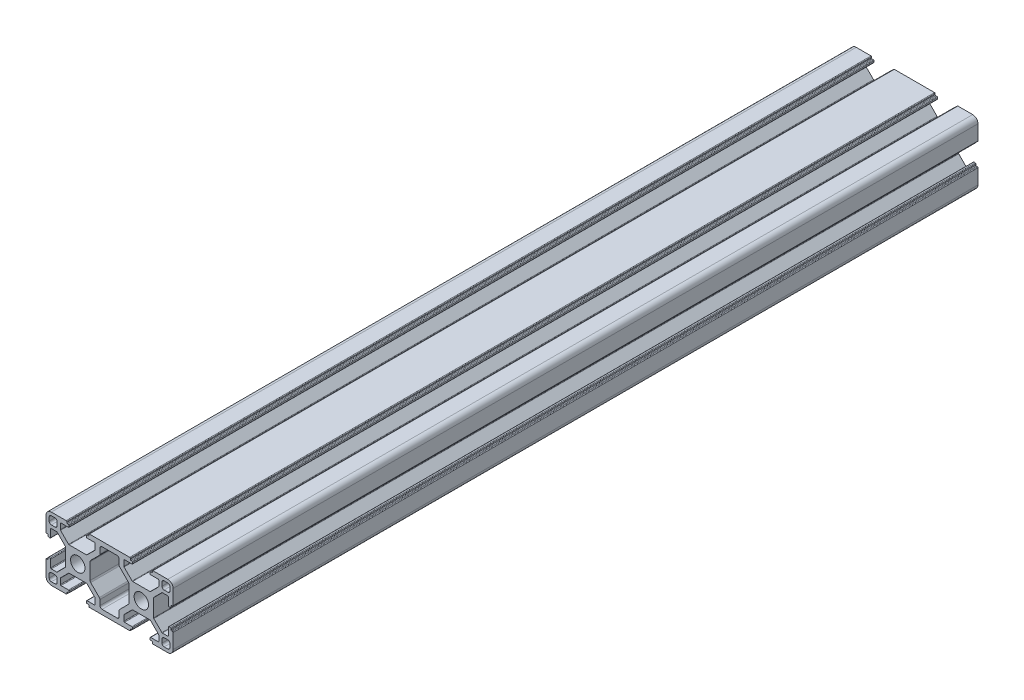
from build123d import *

# Parameters (mm, degrees)
MODEL_R         = 3.4
EXTRUDE_1_DEPTH = 380


with BuildPart() as part:
    # Model → 凸台-拉伸1 (new body)
    with BuildSketch(Plane.XY):
        with BuildLine():
            Line((147.993901934, 59.249179347), (148.493901934, 59.249179347))
            ThreePointArc((148.493901934, 59.249179347), (148.706033968, 59.337047312), (148.793901934, 59.549179347))
            Line((148.793901934, 59.549179347), (148.793901934, 59.949179347))
            ThreePointArc((148.793901934, 59.949179347), (148.881769899, 60.161311381), (149.093901934, 60.249179347))
            Line((149.093901934, 60.249179347), (156.093901934, 60.249179347))
            ThreePointArc((156.093901934, 60.249179347), (157.861668887, 59.5169463), (158.593901934, 57.749179346))
            Line((158.593901934, 57.749179346), (158.593901934, 50.749179347))
            ThreePointArc((158.593901934, 50.749179347), (158.506033968, 50.537047312), (158.293901934, 50.449179347))
            Line((158.293901934, 50.449179347), (157.893901934, 50.449179347))
            ThreePointArc((157.893901934, 50.449179347), (157.6817699, 50.361311381), (157.593901934, 50.149179347))
            Line((157.593901934, 50.149179347), (157.593901934, 49.649179347))
            ThreePointArc((157.593901934, 49.649179347), (157.506033968, 49.437047312), (157.293901934, 49.349179347))
            Line((157.293901934, 49.349179347), (156.693901934, 49.349179347))
            ThreePointArc((156.693901934, 49.349179347), (156.4817699, 49.437047312), (156.393901934, 49.649179347))
            Line((156.393901934, 49.649179347), (156.393901934, 53.199179347))
            ThreePointArc((156.393901934, 53.199179347), (156.306033968, 53.411311381), (156.093901934, 53.499179347))
            Line((156.093901934, 53.499179347), (153.523800921, 53.499179347))
            ThreePointArc((153.523800921, 53.499179347), (153.408995891, 53.476343206), (153.311668887, 53.411311381))
            Line((153.311668887, 53.411311381), (149.4817699, 49.581412394))
            ThreePointArc((149.4817699, 49.581412394), (149.416738074, 49.484085389), (149.393901934, 49.369280359))
            Line((149.393901934, 49.369280359), (149.393901934, 45.249179347))
            Line((149.393901934, 45.249179347), (149.393901934, 41.129078334))
            ThreePointArc((149.393901934, 41.129078334), (149.416738074, 41.014273304), (149.4817699, 40.9169463))
            Line((149.4817699, 40.9169463), (153.311668887, 37.087047312))
            ThreePointArc((153.311668887, 37.087047312), (153.408995891, 37.022015487), (153.523800921, 36.999179347))
            Line((153.523800921, 36.999179347), (156.093901934, 36.999179347))
            ThreePointArc((156.093901934, 36.999179347), (156.306033968, 37.087047312), (156.393901934, 37.299179347))
            Line((156.393901934, 37.299179347), (156.393901934, 40.849179347))
            ThreePointArc((156.393901934, 40.849179347), (156.4817699, 41.061311381), (156.693901934, 41.149179347))
            Line((156.693901934, 41.149179347), (157.293901934, 41.149179347))
            ThreePointArc((157.293901934, 41.149179347), (157.506033968, 41.061311381), (157.593901934, 40.849179347))
            Line((157.593901934, 40.849179347), (157.593901934, 40.349179347))
            ThreePointArc((157.593901934, 40.349179347), (157.6817699, 40.137047312), (157.893901934, 40.049179347))
            Line((157.893901934, 40.049179347), (158.293901934, 40.049179347))
            ThreePointArc((158.293901934, 40.049179347), (158.506033968, 39.961311381), (158.593901934, 39.749179347))
            Line((158.593901934, 39.749179347), (158.593901934, 32.749179347))
            ThreePointArc((158.593901934, 32.749179347), (157.861668887, 30.981412394), (156.093901934, 30.249179347))
            Line((156.093901934, 30.249179347), (149.093901934, 30.249179347))
            ThreePointArc((149.093901934, 30.249179347), (148.881769899, 30.337047312), (148.793901934, 30.549179346))
            Line((148.793901934, 30.549179346), (148.793901934, 30.949179346))
            ThreePointArc((148.793901934, 30.949179346), (148.706033968, 31.161311381), (148.493901934, 31.249179347))
            Line((148.493901934, 31.249179347), (147.993901934, 31.249179347))
            ThreePointArc((147.993901934, 31.249179347), (147.7817699, 31.337047312), (147.693901934, 31.549179347))
            Line((147.693901934, 31.549179347), (147.693901934, 32.149179347))
            ThreePointArc((147.693901934, 32.149179347), (147.7817699, 32.361311381), (147.993901934, 32.449179347))
            Line((147.993901934, 32.449179347), (151.543901934, 32.449179347))
            ThreePointArc((151.543901934, 32.449179347), (151.756033968, 32.537047312), (151.843901934, 32.749179347))
            Line((151.843901934, 32.749179347), (151.843901934, 35.319280359))
            ThreePointArc((151.843901934, 35.319280359), (151.821065794, 35.434085389), (151.756033968, 35.531412394))
            Line((151.756033968, 35.531412394), (147.926134981, 39.361311381))
            ThreePointArc((147.926134981, 39.361311381), (147.828807976, 39.426343206), (147.714002947, 39.449179347))
            Line((147.714002947, 39.449179347), (143.593901934, 39.449179347))
            Line((143.593901934, 39.449179347), (139.473800921, 39.449179347))
            ThreePointArc((139.473800921, 39.449179347), (139.358995892, 39.426343206), (139.261668887, 39.361311381))
            Line((139.261668887, 39.361311381), (135.4317699, 35.531412394))
            ThreePointArc((135.4317699, 35.531412394), (135.366738074, 35.434085389), (135.343901934, 35.319280359))
            Line((135.343901934, 35.319280359), (135.343901934, 32.749179347))
            ThreePointArc((135.343901934, 32.749179347), (135.4317699, 32.537047312), (135.643901934, 32.449179347))
            Line((135.643901934, 32.449179347), (139.193901934, 32.449179347))
            ThreePointArc((139.193901934, 32.449179347), (139.406033968, 32.361311381), (139.493901934, 32.149179347))
            Line((139.493901934, 32.149179347), (139.493901934, 31.549179347))
            ThreePointArc((139.493901934, 31.549179347), (139.406033968, 31.337047312), (139.193901934, 31.249179347))
            Line((139.193901934, 31.249179347), (138.693901934, 31.249179347))
            ThreePointArc((138.693901934, 31.249179347), (138.4817699, 31.161311381), (138.393901934, 30.949179346))
            Line((138.393901934, 30.949179346), (138.393901934, 30.549179347))
            ThreePointArc((138.393901934, 30.549179347), (138.306033968, 30.337047312), (138.093901934, 30.249179347))
            Line((138.093901934, 30.249179347), (119.093901934, 30.249179347))
            ThreePointArc((119.093901934, 30.249179347), (118.8817699, 30.337047312), (118.793901934, 30.549179347))
            Line((118.793901934, 30.549179347), (118.793901934, 30.949179346))
            ThreePointArc((118.793901934, 30.949179346), (118.706033968, 31.161311381), (118.493901934, 31.249179347))
            Line((118.493901934, 31.249179347), (117.993901934, 31.249179347))
            ThreePointArc((117.993901934, 31.249179347), (117.7817699, 31.337047312), (117.693901934, 31.549179347))
            Line((117.693901934, 31.549179347), (117.693901934, 32.149179347))
            ThreePointArc((117.693901934, 32.149179347), (117.7817699, 32.361311381), (117.993901934, 32.449179347))
            Line((117.993901934, 32.449179347), (121.543901934, 32.449179347))
            ThreePointArc((121.543901934, 32.449179347), (121.756033968, 32.537047312), (121.843901934, 32.749179347))
            Line((121.843901934, 32.749179347), (121.843901934, 35.319280359))
            ThreePointArc((121.843901934, 35.319280359), (121.821065794, 35.434085389), (121.756033968, 35.531412394))
            Line((121.756033968, 35.531412394), (117.926134981, 39.361311381))
            ThreePointArc((117.926134981, 39.361311381), (117.828807976, 39.426343206), (117.714002947, 39.449179347))
            Line((117.714002947, 39.449179347), (113.593901934, 39.449179347))
            Line((113.593901934, 39.449179347), (109.473800921, 39.449179347))
            ThreePointArc((109.473800921, 39.449179347), (109.358995892, 39.426343206), (109.261668887, 39.361311381))
            Line((109.261668887, 39.361311381), (105.4317699, 35.531412394))
            ThreePointArc((105.4317699, 35.531412394), (105.366738074, 35.434085389), (105.343901934, 35.319280359))
            Line((105.343901934, 35.319280359), (105.343901934, 32.749179347))
            ThreePointArc((105.343901934, 32.749179347), (105.4317699, 32.537047312), (105.643901934, 32.449179347))
            Line((105.643901934, 32.449179347), (109.193901934, 32.449179347))
            ThreePointArc((109.193901934, 32.449179347), (109.406033968, 32.361311381), (109.493901934, 32.149179347))
            Line((109.493901934, 32.149179347), (109.493901934, 31.549179347))
            ThreePointArc((109.493901934, 31.549179347), (109.406033968, 31.337047312), (109.193901934, 31.249179347))
            Line((109.193901934, 31.249179347), (108.693901934, 31.249179347))
            ThreePointArc((108.693901934, 31.249179347), (108.4817699, 31.161311381), (108.393901934, 30.949179346))
            Line((108.393901934, 30.949179346), (108.393901934, 30.549179346))
            ThreePointArc((108.393901934, 30.549179346), (108.306033968, 30.337047312), (108.093901934, 30.249179347))
            Line((108.093901934, 30.249179347), (101.093901934, 30.249179347))
            ThreePointArc((101.093901934, 30.249179347), (99.326134981, 30.981412394), (98.593901934, 32.749179347))
            Line((98.593901934, 32.749179347), (98.593901934, 39.749179347))
            ThreePointArc((98.593901934, 39.749179347), (98.6817699, 39.961311381), (98.893901934, 40.049179347))
            Line((98.893901934, 40.049179347), (99.293901934, 40.049179347))
            ThreePointArc((99.293901934, 40.049179347), (99.506033968, 40.137047312), (99.593901934, 40.349179347))
            Line((99.593901934, 40.349179347), (99.593901934, 40.849179347))
            ThreePointArc((99.593901934, 40.849179347), (99.6817699, 41.061311381), (99.893901934, 41.149179347))
            Line((99.893901934, 41.149179347), (100.493901934, 41.149179347))
            ThreePointArc((100.493901934, 41.149179347), (100.706033968, 41.061311381), (100.793901934, 40.849179347))
            Line((100.793901934, 40.849179347), (100.793901934, 37.299179347))
            ThreePointArc((100.793901934, 37.299179347), (100.8817699, 37.087047312), (101.093901934, 36.999179347))
            Line((101.093901934, 36.999179347), (103.664002947, 36.999179347))
            ThreePointArc((103.664002947, 36.999179347), (103.778807976, 37.022015487), (103.876134981, 37.087047312))
            Line((103.876134981, 37.087047312), (107.706033968, 40.9169463))
            ThreePointArc((107.706033968, 40.9169463), (107.771065794, 41.014273304), (107.793901934, 41.129078334))
            Line((107.793901934, 41.129078334), (107.793901934, 45.249179347))
            Line((107.793901934, 45.249179347), (107.793901934, 49.369280359))
            ThreePointArc((107.793901934, 49.369280359), (107.771065794, 49.484085389), (107.706033968, 49.581412394))
            Line((107.706033968, 49.581412394), (103.876134981, 53.411311381))
            ThreePointArc((103.876134981, 53.411311381), (103.778807976, 53.476343206), (103.664002947, 53.499179347))
            Line((103.664002947, 53.499179347), (101.093901934, 53.499179347))
            ThreePointArc((101.093901934, 53.499179347), (100.8817699, 53.411311381), (100.793901934, 53.199179347))
            Line((100.793901934, 53.199179347), (100.793901934, 49.649179347))
            ThreePointArc((100.793901934, 49.649179347), (100.706033968, 49.437047312), (100.493901934, 49.349179347))
            Line((100.493901934, 49.349179347), (99.893901934, 49.349179347))
            ThreePointArc((99.893901934, 49.349179347), (99.6817699, 49.437047312), (99.593901934, 49.649179347))
            Line((99.593901934, 49.649179347), (99.593901934, 50.149179347))
            ThreePointArc((99.593901934, 50.149179347), (99.506033968, 50.361311381), (99.293901934, 50.449179347))
            Line((99.293901934, 50.449179347), (98.893901934, 50.449179347))
            ThreePointArc((98.893901934, 50.449179347), (98.6817699, 50.537047312), (98.593901934, 50.749179347))
            Line((98.593901934, 50.749179347), (98.593901934, 57.749179346))
            ThreePointArc((98.593901934, 57.749179346), (99.326134981, 59.5169463), (101.093901934, 60.249179347))
            Line((101.093901934, 60.249179347), (108.093901934, 60.249179347))
            ThreePointArc((108.093901934, 60.249179347), (108.306033968, 60.161311381), (108.393901934, 59.949179347))
            Line((108.393901934, 59.949179347), (108.393901934, 59.549179347))
            ThreePointArc((108.393901934, 59.549179347), (108.4817699, 59.337047312), (108.693901934, 59.249179347))
            Line((108.693901934, 59.249179347), (109.193901934, 59.249179347))
            ThreePointArc((109.193901934, 59.249179347), (109.406033968, 59.161311381), (109.493901934, 58.949179347))
            Line((109.493901934, 58.949179347), (109.493901934, 58.349179347))
            ThreePointArc((109.493901934, 58.349179347), (109.406033968, 58.137047312), (109.193901934, 58.049179347))
            Line((109.193901934, 58.049179347), (105.643901934, 58.049179347))
            ThreePointArc((105.643901934, 58.049179347), (105.4317699, 57.961311381), (105.343901934, 57.749179347))
            Line((105.343901934, 57.749179347), (105.343901934, 55.179078334))
            ThreePointArc((105.343901934, 55.179078334), (105.366738074, 55.064273304), (105.4317699, 54.9669463))
            Line((105.4317699, 54.9669463), (109.261668887, 51.137047312))
            ThreePointArc((109.261668887, 51.137047312), (109.358995892, 51.072015487), (109.473800921, 51.049179347))
            Line((109.473800921, 51.049179347), (113.593901934, 51.049179347))
            Line((113.593901934, 51.049179347), (117.714002947, 51.049179347))
            ThreePointArc((117.714002947, 51.049179347), (117.828807976, 51.072015487), (117.926134981, 51.137047312))
            Line((117.926134981, 51.137047312), (121.756033968, 54.9669463))
            ThreePointArc((121.756033968, 54.9669463), (121.821065794, 55.064273304), (121.843901934, 55.179078334))
            Line((121.843901934, 55.179078334), (121.843901934, 57.749179347))
            ThreePointArc((121.843901934, 57.749179347), (121.756033968, 57.961311381), (121.543901934, 58.049179347))
            Line((121.543901934, 58.049179347), (117.993901934, 58.049179347))
            ThreePointArc((117.993901934, 58.049179347), (117.7817699, 58.137047312), (117.693901934, 58.349179347))
            Line((117.693901934, 58.349179347), (117.693901934, 58.949179347))
            ThreePointArc((117.693901934, 58.949179347), (117.7817699, 59.161311381), (117.993901934, 59.249179347))
            Line((117.993901934, 59.249179347), (118.493901934, 59.249179347))
            ThreePointArc((118.493901934, 59.249179347), (118.706033968, 59.337047312), (118.793901934, 59.549179347))
            Line((118.793901934, 59.549179347), (118.793901934, 59.949179347))
            ThreePointArc((118.793901934, 59.949179347), (118.881769899, 60.161311381), (119.093901934, 60.249179347))
            Line((119.093901934, 60.249179347), (138.093901934, 60.249179347))
            ThreePointArc((138.093901934, 60.249179347), (138.306033968, 60.161311381), (138.393901934, 59.949179347))
            Line((138.393901934, 59.949179347), (138.393901934, 59.549179347))
            ThreePointArc((138.393901934, 59.549179347), (138.4817699, 59.337047312), (138.693901934, 59.249179347))
            Line((138.693901934, 59.249179347), (139.193901934, 59.249179347))
            ThreePointArc((139.193901934, 59.249179347), (139.406033968, 59.161311381), (139.493901934, 58.949179347))
            Line((139.493901934, 58.949179347), (139.493901934, 58.349179347))
            ThreePointArc((139.493901934, 58.349179347), (139.406033968, 58.137047312), (139.193901934, 58.049179347))
            Line((139.193901934, 58.049179347), (135.643901934, 58.049179347))
            ThreePointArc((135.643901934, 58.049179347), (135.4317699, 57.961311381), (135.343901934, 57.749179347))
            Line((135.343901934, 57.749179347), (135.343901934, 55.179078334))
            ThreePointArc((135.343901934, 55.179078334), (135.366738074, 55.064273304), (135.4317699, 54.9669463))
            Line((135.4317699, 54.9669463), (139.261668887, 51.137047312))
            ThreePointArc((139.261668887, 51.137047312), (139.358995892, 51.072015487), (139.473800921, 51.049179347))
            Line((139.473800921, 51.049179347), (143.593901934, 51.049179347))
            Line((143.593901934, 51.049179347), (147.714002947, 51.049179347))
            ThreePointArc((147.714002947, 51.049179347), (147.828807976, 51.072015487), (147.926134981, 51.137047312))
            Line((147.926134981, 51.137047312), (151.756033968, 54.9669463))
            ThreePointArc((151.756033968, 54.9669463), (151.821065794, 55.064273304), (151.843901934, 55.179078334))
            Line((151.843901934, 55.179078334), (151.843901934, 57.749179347))
            ThreePointArc((151.843901934, 57.749179347), (151.756033968, 57.961311381), (151.543901934, 58.049179347))
            Line((151.543901934, 58.049179347), (147.993901934, 58.049179347))
            ThreePointArc((147.993901934, 58.049179347), (147.7817699, 58.137047312), (147.693901934, 58.349179347))
            Line((147.693901934, 58.349179347), (147.693901934, 58.949179347))
            ThreePointArc((147.693901934, 58.949179347), (147.7817699, 59.161311381), (147.993901934, 59.249179347))
        make_face()
        with Locations((113.593901934, 45.249179347)):
            Circle(MODEL_R, mode=Mode.SUBTRACT)
        with Locations((143.593901934, 45.249179347)):
            Circle(MODEL_R, mode=Mode.SUBTRACT)
        with BuildLine():
            Line((154.343901934, 58.749179347), (156.093901934, 58.749179347))
            ThreePointArc((156.093901934, 58.749179347), (156.801008715, 58.456286128), (157.093901934, 57.749179347))
            Line((157.093901934, 57.749179347), (157.093901934, 55.999179347))
            ThreePointArc((157.093901934, 55.999179347), (156.801008715, 55.292072565), (156.093901934, 54.999179347))
            Line((156.093901934, 54.999179347), (154.343901934, 54.999179347))
            ThreePointArc((154.343901934, 54.999179347), (153.636795153, 55.292072565), (153.343901934, 55.999179347))
            Line((153.343901934, 55.999179347), (153.343901934, 57.749179347))
            ThreePointArc((153.343901934, 57.749179347), (153.636795153, 58.456286128), (154.343901934, 58.749179347))
        make_face(mode=Mode.SUBTRACT)
        with BuildLine():
            Line((102.843901934, 58.749179347), (101.093901934, 58.749179347))
            ThreePointArc((101.093901934, 58.749179347), (100.386795153, 58.456286128), (100.093901934, 57.749179347))
            Line((100.093901934, 57.749179347), (100.093901934, 55.999179347))
            ThreePointArc((100.093901934, 55.999179347), (100.386795153, 55.292072565), (101.093901934, 54.999179347))
            Line((101.093901934, 54.999179347), (102.843901934, 54.999179347))
            ThreePointArc((102.843901934, 54.999179347), (103.551008715, 55.292072565), (103.843901934, 55.999179347))
            Line((103.843901934, 55.999179347), (103.843901934, 57.749179347))
            ThreePointArc((103.843901934, 57.749179347), (103.551008715, 58.456286128), (102.843901934, 58.749179347))
        make_face(mode=Mode.SUBTRACT)
        with BuildLine():
            Line((154.343901934, 31.749179347), (156.093901934, 31.749179347))
            ThreePointArc((156.093901934, 31.749179347), (156.801008715, 32.042072565), (157.093901934, 32.749179347))
            Line((157.093901934, 32.749179347), (157.093901934, 34.499179347))
            ThreePointArc((157.093901934, 34.499179347), (156.801008715, 35.206286128), (156.093901934, 35.499179347))
            Line((156.093901934, 35.499179347), (154.343901934, 35.499179347))
            ThreePointArc((154.343901934, 35.499179347), (153.636795153, 35.206286128), (153.343901934, 34.499179347))
            Line((153.343901934, 34.499179347), (153.343901934, 32.749179347))
            ThreePointArc((153.343901934, 32.749179347), (153.636795153, 32.042072565), (154.343901934, 31.749179347))
        make_face(mode=Mode.SUBTRACT)
        with BuildLine():
            Line((119.393901934, 49.079330866), (119.393901934, 45.249179347))
            Line((119.393901934, 45.249179347), (119.393901934, 41.419027828))
            ThreePointArc((119.393901934, 41.419027828), (119.470022401, 41.036344395), (119.686795153, 40.711921046))
            Line((119.686795153, 40.711921046), (123.751008715, 36.647707484))
            ThreePointArc((123.751008715, 36.647707484), (123.967781466, 36.323284135), (124.043901934, 35.940600703))
            Line((124.043901934, 35.940600703), (124.043901934, 33.449179347))
            ThreePointArc((124.043901934, 33.449179347), (124.336795153, 32.742072565), (125.043901934, 32.449179347))
            Line((125.043901934, 32.449179347), (128.593901934, 32.449179347))
            Line((128.593901934, 32.449179347), (132.143901934, 32.449179347))
            ThreePointArc((132.143901934, 32.449179347), (132.851008715, 32.742072565), (133.143901934, 33.449179347))
            Line((133.143901934, 33.449179347), (133.143901934, 35.940600703))
            ThreePointArc((133.143901934, 35.940600703), (133.220022401, 36.323284135), (133.436795153, 36.647707484))
            Line((133.436795153, 36.647707484), (137.501008715, 40.711921046))
            ThreePointArc((137.501008715, 40.711921046), (137.717781466, 41.036344395), (137.793901934, 41.419027828))
            Line((137.793901934, 41.419027828), (137.793901934, 45.249179347))
            Line((137.793901934, 45.249179347), (137.793901934, 49.079330866))
            ThreePointArc((137.793901934, 49.079330866), (137.717781466, 49.462014298), (137.501008715, 49.786437647))
            Line((137.501008715, 49.786437647), (133.436795153, 53.850651209))
            ThreePointArc((133.436795153, 53.850651209), (133.220022401, 54.175074558), (133.143901934, 54.55775799))
            Line((133.143901934, 54.55775799), (133.143901934, 57.049179347))
            ThreePointArc((133.143901934, 57.049179347), (132.851008715, 57.756286128), (132.143901934, 58.049179347))
            Line((132.143901934, 58.049179347), (128.593901934, 58.049179347))
            Line((128.593901934, 58.049179347), (125.043901934, 58.049179347))
            ThreePointArc((125.043901934, 58.049179347), (124.336795153, 57.756286128), (124.043901934, 57.049179347))
            Line((124.043901934, 57.049179347), (124.043901934, 54.55775799))
            ThreePointArc((124.043901934, 54.55775799), (123.967781466, 54.175074558), (123.751008715, 53.850651209))
            Line((123.751008715, 53.850651209), (119.686795153, 49.786437647))
            ThreePointArc((119.686795153, 49.786437647), (119.470022401, 49.462014298), (119.393901934, 49.079330866))
        make_face(mode=Mode.SUBTRACT)
        with BuildLine():
            Line((102.843901934, 31.749179347), (101.093901934, 31.749179347))
            ThreePointArc((101.093901934, 31.749179347), (100.386795153, 32.042072565), (100.093901934, 32.749179347))
            Line((100.093901934, 32.749179347), (100.093901934, 34.499179347))
            ThreePointArc((100.093901934, 34.499179347), (100.386795153, 35.206286128), (101.093901934, 35.499179347))
            Line((101.093901934, 35.499179347), (102.843901934, 35.499179347))
            ThreePointArc((102.843901934, 35.499179347), (103.551008715, 35.206286128), (103.843901934, 34.499179347))
            Line((103.843901934, 34.499179347), (103.843901934, 32.749179347))
            ThreePointArc((103.843901934, 32.749179347), (103.551008715, 32.042072565), (102.843901934, 31.749179347))
        make_face(mode=Mode.SUBTRACT)
    extrude(amount=EXTRUDE_1_DEPTH)


solid = part.part
